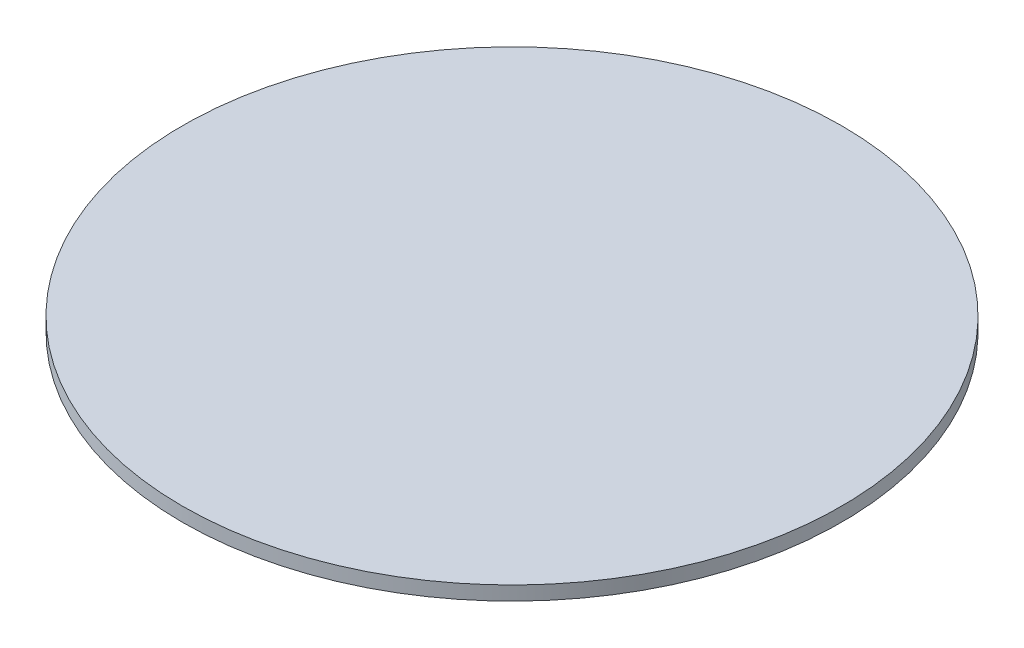
from build123d import *

# Parameters (mm, degrees)
SKETCH1_R           = 40
BOSS_EXTRUDE1_DEPTH = 1.7


with BuildPart() as part:
    # Sketch1 → Boss-Extrude1 (new body)
    with BuildSketch(Plane(origin=(0, 0, 0), x_dir=(1, 0, 0), z_dir=(0, 1, 0))):
        Circle(SKETCH1_R)
    extrude(amount=BOSS_EXTRUDE1_DEPTH)


solid = part.part
